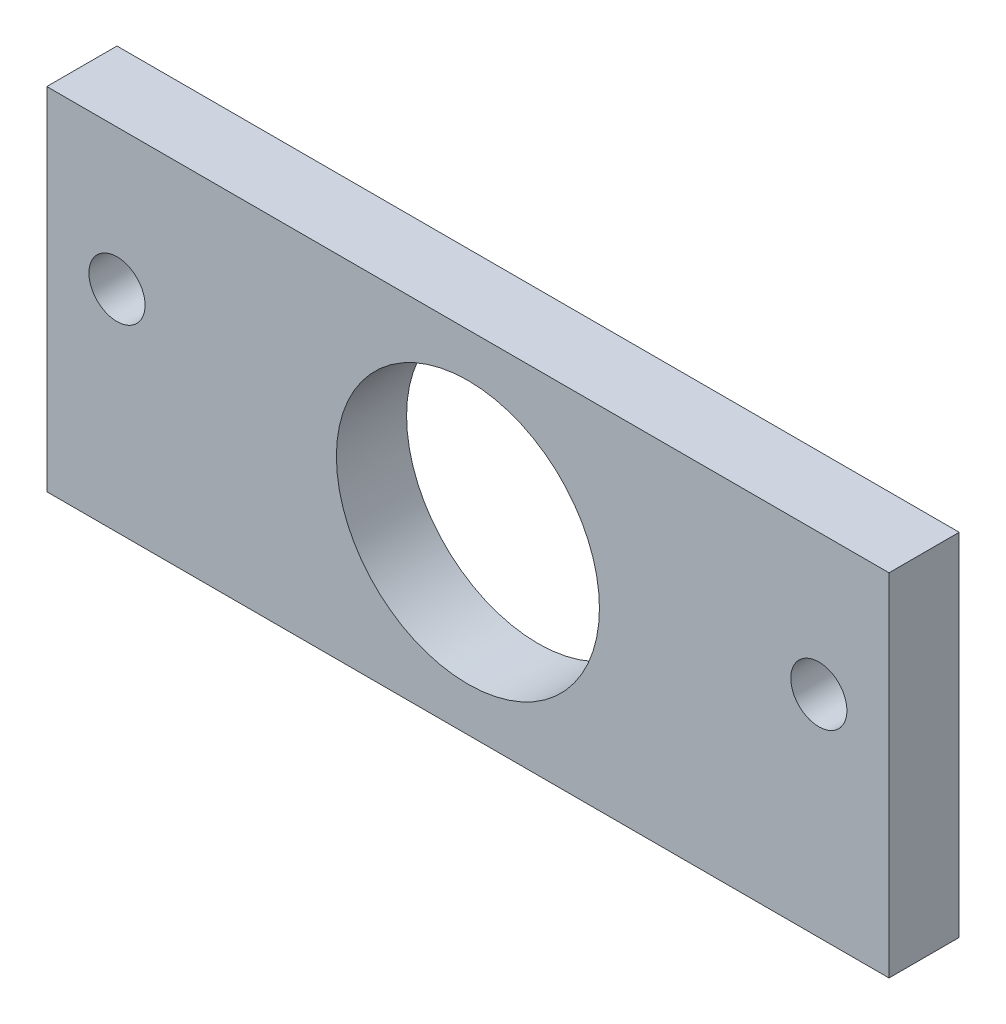
from build123d import *

# Parameters (mm, degrees)
SKETCH1_W           = 76.2
SKETCH1_H           = 31.75
SKETCH1_R           = 11.8999
SKETCH1_R_2         = 2.54
BOSS_EXTRUDE1_DEPTH = 6.35


with BuildPart() as part:
    # Sketch1 → Boss-Extrude1 (new body)
    with BuildSketch(Plane.XY):
        with Locations((38.1, 15.875)):
            Rectangle(SKETCH1_W, SKETCH1_H)
        with Locations((38.1, 15.875)):
            Circle(SKETCH1_R, mode=Mode.SUBTRACT)
        with Locations((6.35, 19.05)):
            Circle(SKETCH1_R_2, mode=Mode.SUBTRACT)
        with Locations((69.85, 19.05)):
            Circle(SKETCH1_R_2, mode=Mode.SUBTRACT)
    extrude(amount=BOSS_EXTRUDE1_DEPTH)


solid = part.part
